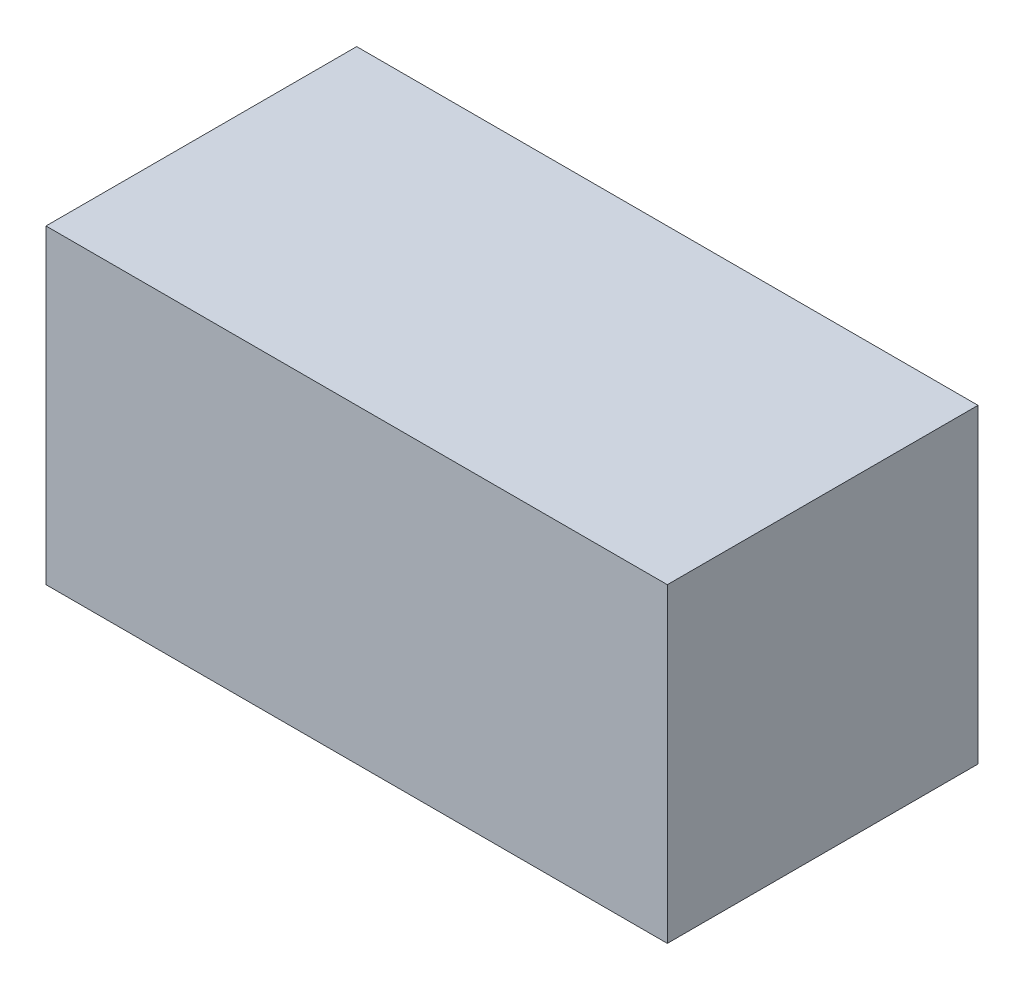
from build123d import *

# Parameters (mm, degrees)
SKETCH1_W           = 20
SKETCH1_H           = 10
BOSS_EXTRUDE1_DEPTH = 5


with BuildPart() as part:
    # Sketch1 → Boss-Extrude1 (new body, symmetric)
    with BuildSketch(Plane(origin=(0, 0, 0), x_dir=(1, 0, 0), z_dir=(0, 1, 0))):
        Rectangle(SKETCH1_W, SKETCH1_H)
    extrude(amount=BOSS_EXTRUDE1_DEPTH, both=True)


solid = part.part
